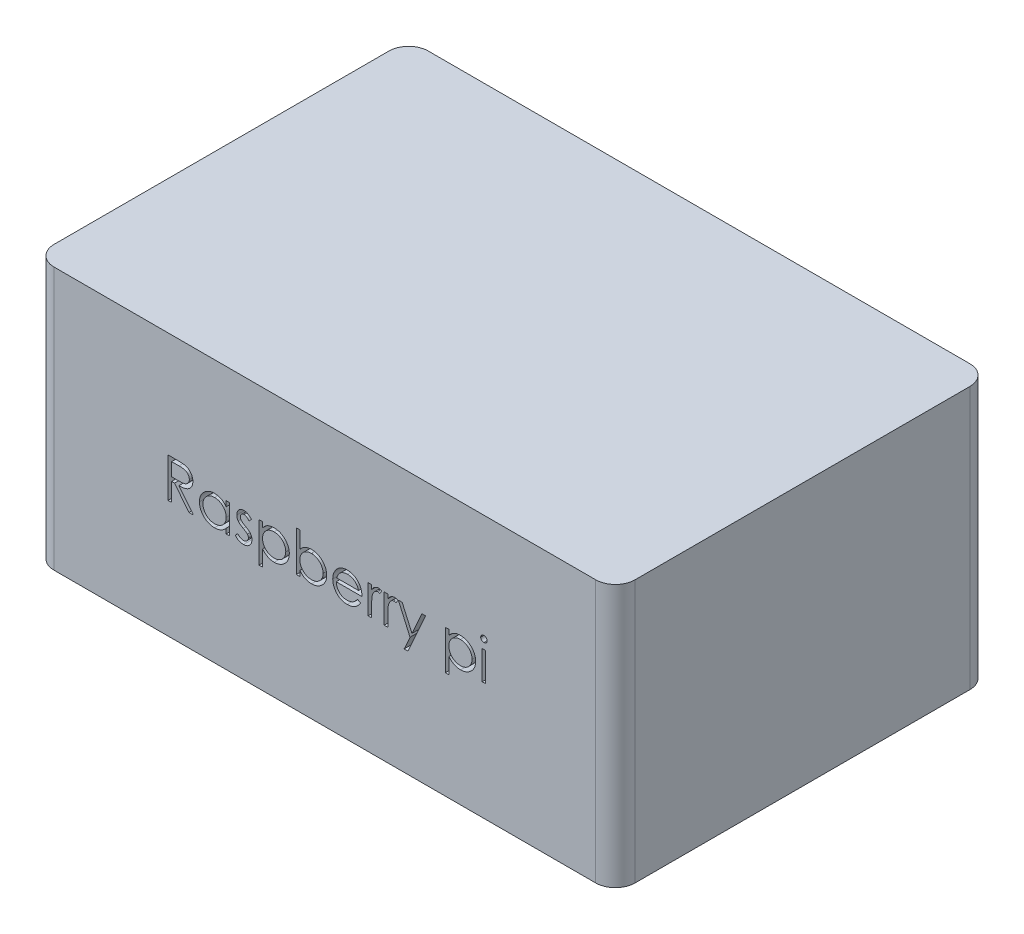
from build123d import *

# Parameters (mm, degrees)
CROQUIS1_W              = 88.5
CROQUIS1_H              = 57
SALIENTE_EXTRUIR1_DEPTH = 40
CROQUIS2_W              = 0.538461538
CROQUIS2_H              = 4.384615384
CORTAR_EXTRUIR1_DEPTH   = 4
REDONDEO1_R             = 3


with BuildPart() as part:
    # Croquis1 → Saliente-Extruir1 (new body)
    with BuildSketch(Plane(origin=(0, 0, 0), x_dir=(1, 0, 0), z_dir=(0, 1, 0))):
        with Locations((-14.949438202, 10.887640449)):
            Rectangle(CROQUIS1_W, CROQUIS1_H)
    extrude(amount=SALIENTE_EXTRUIR1_DEPTH)

    # Croquis2 → Cortar-Extruir1 (cut)
    with BuildSketch(Plane.XY.offset(17.612359551)):
        with BuildLine():
            Line((-38.833665017, 23.901066202), (-37.632943863, 23.901066202))
            add(Edge.make_bspline(
                [(-37.632943863, 23.901066202), (-37.552816215, 23.900799483), (-37.398962253, 23.900287353), (-37.178550932, 23.89743176), (-36.978275909, 23.88924715), (-36.798241898, 23.882203864), (-36.638452204, 23.869360536), (-36.498416849, 23.857085141), (-36.378780796, 23.841016008), (-36.306359336, 23.826092426), (-36.273568863, 23.819335433)],
                knots=[0, 0, 0, 0, 0.000240388, 0.000461571, 0.00066122, 0.000841705, 0.001002012, 0.001142061, 0.001263425, 0.001363841, 0.001363841, 0.001363841, 0.001363841], degree=3))
            add(Edge.make_bspline(
                [(-36.273568863, 23.819335433), (-36.229671794, 23.808489549), (-36.142814097, 23.787029154), (-36.017756841, 23.741669839), (-35.898589429, 23.689179053), (-35.785806873, 23.627526961), (-35.679974088, 23.556255911), (-35.579999841, 23.476596272), (-35.485430475, 23.388983919), (-35.400090538, 23.291209905), (-35.319623592, 23.188633032), (-35.251757375, 23.077712306), (-35.193254838, 22.961721116), (-35.146676809, 22.839479828), (-35.109171712, 22.712173933), (-35.08272673, 22.578650282), (-35.066867551, 22.439517182), (-35.065252942, 22.34461791), (-35.064434248, 22.296498894)],
                knots=[0, 0, 0, 0, 0.000135567, 0.000268242, 0.000398455, 0.000525939, 0.00065328, 0.000780735, 0.000909138, 0.001039396, 0.001169693, 0.001299773, 0.001428776, 0.001558907, 0.001691647, 0.001826477, 0.001966773, 0.002111084, 0.002111084, 0.002111084, 0.002111084], degree=3))
            add(Edge.make_bspline(
                [(-35.064434248, 22.296498894), (-35.066952531, 22.216553), (-35.071866352, 22.060557856), (-35.117680815, 21.834167773), (-35.192726278, 21.622986091), (-35.29613763, 21.427278712), (-35.42782816, 21.250860462), (-35.586099231, 21.095905396), (-35.771039136, 20.966236975), (-35.943203678, 20.876317881), (-36.095285163, 20.818730037), (-36.220485128, 20.778210565), (-36.357057089, 20.746904339), (-36.50369252, 20.718858399), (-36.661001643, 20.697684065), (-36.828607425, 20.682175618), (-37.0066294, 20.672482963), (-37.128924947, 20.671039526), (-37.191838094, 20.670296971)],
                knots=[0, 0, 0, 0, 0.000239617, 0.000467555, 0.00068957, 0.000910017, 0.001129008, 0.001347444, 0.001571557, 0.001804323, 0.001927981, 0.002059123, 0.002198764, 0.002347981, 0.002506913, 0.002674709, 0.002852853, 0.00304159, 0.00304159, 0.00304159, 0.00304159], degree=3))
            Line((-37.191838094, 20.670296971), (-34.987511171, 17.901066202))
            Line((-34.987511171, 17.901066202), (-35.653376556, 17.901066202))
            Line((-35.653376556, 17.901066202), (-37.857703479, 20.670296971))
            Line((-37.857703479, 20.670296971), (-38.295203479, 20.670296971))
            Line((-38.295203479, 20.670296971), (-38.295203479, 17.901066202))
            Line((-38.295203479, 17.901066202), (-38.833665017, 17.901066202))
            Line((-38.833665017, 17.901066202), (-38.833665017, 23.901066202))
        make_face()
        with BuildLine():
            Line((-38.295203479, 23.285681586), (-38.295203479, 21.285681586))
            Line((-38.295203479, 21.285681586), (-37.196645787, 21.277268125))
            add(Edge.make_bspline(
                [(-37.196645787, 21.277268125), (-37.145354291, 21.277245433), (-37.045936765, 21.277201451), (-36.902107054, 21.284047925), (-36.768186862, 21.29183647), (-36.64468843, 21.303749634), (-36.531556587, 21.3191029), (-36.428847878, 21.338308016), (-36.336394646, 21.36068298), (-36.22856858, 21.395314339), (-36.108163098, 21.450181799), (-35.977309167, 21.530008368), (-35.865876588, 21.630412572), (-35.771731681, 21.745224211), (-35.696081227, 21.87145778), (-35.642746277, 22.007600128), (-35.60890209, 22.150214296), (-35.604910298, 22.248233909), (-35.602895787, 22.297700817)],
                knots=[0, 0, 0, 0, 0.000153851, 0.000298207, 0.000431885, 0.000556265, 0.000670322, 0.000774279, 0.000869603, 0.000955505, 0.001113666, 0.001265404, 0.001413529, 0.001561267, 0.001709475, 0.001852988, 0.00199848, 0.002146712, 0.002146712, 0.002146712, 0.002146712], degree=3))
            add(Edge.make_bspline(
                [(-35.602895787, 22.297700817), (-35.604956566, 22.345952086), (-35.609040278, 22.441568496), (-35.642381024, 22.581550056), (-35.69876282, 22.713664828), (-35.7747438, 22.837375373), (-35.86731378, 22.949670921), (-35.975858601, 23.045751754), (-36.097410364, 23.125036551), (-36.211018133, 23.175701203), (-36.312562497, 23.206763809), (-36.400727629, 23.228622947), (-36.500347305, 23.246184894), (-36.611905234, 23.260255855), (-36.734925172, 23.272350045), (-36.870029146, 23.280495951), (-37.016320769, 23.285319719), (-37.117715508, 23.285558157), (-37.170203479, 23.285681586)],
                knots=[0, 0, 0, 0, 0.000144636, 0.000286615, 0.000428814, 0.000573933, 0.000720745, 0.000863779, 0.001007131, 0.001154551, 0.001235143, 0.001325511, 0.001426887, 0.0015384, 0.001662781, 0.001797659, 0.001944372, 0.002101829, 0.002101829, 0.002101829, 0.002101829], degree=3))
            Line((-37.170203479, 23.285681586), (-38.295203479, 23.285681586))
        make_face(mode=Mode.SUBTRACT)
        with BuildLine():
            Line((-29.449049633, 22.285681586), (-29.449049633, 17.901066202))
            Line((-29.449049633, 17.901066202), (-29.987511171, 17.901066202))
            Line((-29.987511171, 17.901066202), (-29.987511171, 18.659479663))
            add(Edge.make_bspline(
                [(-29.987511171, 18.659479663), (-30.048229098, 18.590840359), (-30.166720896, 18.456889895), (-30.364619955, 18.281891885), (-30.574393974, 18.137243333), (-30.79502481, 18.020414907), (-31.026313228, 17.932657096), (-31.26774652, 17.870280823), (-31.519423173, 17.830177105), (-31.691284353, 17.826172497), (-31.778376556, 17.824143125)],
                knots=[0, 0, 0, 0, 0.000274736, 0.000536151, 0.000790198, 0.001037514, 0.001283277, 0.001530491, 0.00178462, 0.002045714, 0.002045714, 0.002045714, 0.002045714], degree=3))
            add(Edge.make_bspline(
                [(-31.778376556, 17.824143125), (-31.855807334, 17.826245477), (-32.008504256, 17.830391409), (-32.233125532, 17.862555359), (-32.449283673, 17.914207853), (-32.657182941, 17.986037949), (-32.855478047, 18.081319358), (-33.045866785, 18.195390068), (-33.227362828, 18.331231491), (-33.397199752, 18.486525254), (-33.553597467, 18.655202375), (-33.690845363, 18.835109027), (-33.805279214, 19.025467262), (-33.900970781, 19.223866955), (-33.9746788, 19.431835388), (-34.026062173, 19.64865339), (-34.058188653, 19.874064602), (-34.062332871, 20.027560927), (-34.064434248, 20.105393125)],
                knots=[0, 0, 0, 0, 0.000232223, 0.000457954, 0.000679219, 0.000898167, 0.001116441, 0.001338029, 0.00156303, 0.001795312, 0.00202752, 0.002252283, 0.002472841, 0.002692718, 0.002912064, 0.003133329, 0.003360251, 0.003593675, 0.003593675, 0.003593675, 0.003593675], degree=3))
            add(Edge.make_bspline(
                [(-34.064434248, 20.105393125), (-34.062286297, 20.181616617), (-34.058039914, 20.332306348), (-34.026405823, 20.553926973), (-33.973209808, 20.767386849), (-33.898556355, 20.971998751), (-33.802827289, 21.168010266), (-33.68637914, 21.355560023), (-33.549203498, 21.535164704), (-33.391056514, 21.702601093), (-33.219739765, 21.857265003), (-33.036467655, 21.99168051), (-32.845799173, 22.107766537), (-32.644776869, 22.199743924), (-32.436376118, 22.274159532), (-32.21874164, 22.32564462), (-31.992778933, 22.355982885), (-31.839366661, 22.360376195), (-31.761549633, 22.362604663)],
                knots=[0, 0, 0, 0, 0.000228621, 0.000451972, 0.000670021, 0.000887513, 0.001104142, 0.001323278, 0.00154877, 0.001780915, 0.002013284, 0.002240216, 0.002461804, 0.002681742, 0.002902222, 0.003124656, 0.003351415, 0.003584839, 0.003584839, 0.003584839, 0.003584839], degree=3))
            add(Edge.make_bspline(
                [(-31.761549633, 22.362604663), (-31.67206416, 22.360139946), (-31.496587372, 22.355306753), (-31.239910784, 22.315084935), (-30.997091679, 22.247133277), (-30.766255647, 22.15470328), (-30.548231614, 22.031876887), (-30.345083641, 21.876939811), (-30.154685669, 21.690869205), (-30.044319455, 21.547948443), (-29.987511171, 21.474383509)],
                knots=[0, 0, 0, 0, 0.000268355, 0.000526231, 0.000777018, 0.001023424, 0.001270454, 0.001525265, 0.001787892, 0.002066459, 0.002066459, 0.002066459, 0.002066459], degree=3))
            Line((-29.987511171, 21.474383509), (-29.987511171, 22.285681586))
            Line((-29.987511171, 22.285681586), (-29.449049633, 22.285681586))
        make_face()
        with BuildLine():
            add(Edge.make_bspline(
                [(-31.754338094, 21.824143125), (-31.833048388, 21.821342603), (-31.988409988, 21.815814818), (-32.21648542, 21.772660255), (-32.434736987, 21.700858093), (-32.642073114, 21.602660549), (-32.835218628, 21.479182714), (-33.00783635, 21.329831772), (-33.161338124, 21.158682604), (-33.290438005, 20.966507558), (-33.395678857, 20.760487973), (-33.469679483, 20.545131794), (-33.518483907, 20.324323261), (-33.523469942, 20.174558657), (-33.52597271, 20.099383509)],
                knots=[0, 0, 0, 0, 0.000236018, 0.000465862, 0.000693534, 0.000923642, 0.001152351, 0.00137906, 0.001606338, 0.001840024, 0.002071696, 0.002298245, 0.002521713, 0.002746934, 0.002746934, 0.002746934, 0.002746934], degree=3))
            add(Edge.make_bspline(
                [(-33.52597271, 20.099383509), (-33.52277575, 20.024657611), (-33.516394361, 19.875498716), (-33.470536028, 19.654389155), (-33.393599102, 19.438982226), (-33.288612708, 19.231106237), (-33.157149923, 19.038104922), (-33.004769376, 18.863693284), (-32.829997465, 18.713711132), (-32.636407453, 18.588161006), (-32.429650932, 18.486739542), (-32.212221335, 18.416169874), (-31.988205956, 18.370607964), (-31.835887669, 18.365286004), (-31.759145787, 18.362604663)],
                knots=[0, 0, 0, 0, 0.000224103, 0.000447328, 0.000674275, 0.000908634, 0.001143991, 0.001373066, 0.00160147, 0.001832496, 0.002063643, 0.002290173, 0.0025167, 0.00274672, 0.00274672, 0.00274672, 0.00274672], degree=3))
            add(Edge.make_bspline(
                [(-31.759145787, 18.362604663), (-31.681237496, 18.365450316), (-31.526285634, 18.371110036), (-31.297533563, 18.414449348), (-31.075542198, 18.486053002), (-30.863335521, 18.585308648), (-30.665650725, 18.708321258), (-30.488225792, 18.852333414), (-30.338198417, 19.019824587), (-30.211011086, 19.203898507), (-30.111281801, 19.405690501), (-30.038637128, 19.620549113), (-29.995687575, 19.848481824), (-29.990274324, 20.004248556), (-29.987511171, 20.083758509)],
                knots=[0, 0, 0, 0, 0.000233619, 0.000464644, 0.000695745, 0.000931803, 0.001165589, 0.001392736, 0.001614832, 0.001837866, 0.002062011, 0.00228778, 0.002516443, 0.00275486, 0.00275486, 0.00275486, 0.00275486], degree=3))
            add(Edge.make_bspline(
                [(-29.987511171, 20.083758509), (-29.989156296, 20.144337647), (-29.992394423, 20.263576562), (-30.017132543, 20.438652306), (-30.056483845, 20.606195837), (-30.111934422, 20.766383303), (-30.184776624, 20.918329044), (-30.272629937, 21.063124062), (-30.377039279, 21.200015281), (-30.496323901, 21.327117689), (-30.62689282, 21.443048767), (-30.76505489, 21.546530322), (-30.912447027, 21.631539647), (-31.066590519, 21.701896112), (-31.227752807, 21.757883226), (-31.397245298, 21.795233559), (-31.573266418, 21.820879823), (-31.69334537, 21.823043905), (-31.754338094, 21.824143125)],
                knots=[0, 0, 0, 0, 0.000181685, 0.000357614, 0.000529325, 0.000697337, 0.000865073, 0.001033895, 0.001204572, 0.0013806, 0.001555973, 0.001727852, 0.001897511, 0.00206532, 0.002235604, 0.002408212, 0.002585332, 0.002768167, 0.002768167, 0.002768167, 0.002768167], degree=3))
        make_face(mode=Mode.SUBTRACT)
        with BuildLine():
            Line((-26.141357325, 21.738806586), (-26.50674194, 21.362604663))
            add(Edge.make_bspline(
                [(-26.50674194, 21.362604663), (-26.538268518, 21.399141486), (-26.599048048, 21.469580178), (-26.695444872, 21.563758006), (-26.791485336, 21.642849901), (-26.88585473, 21.709625202), (-26.980926049, 21.760109454), (-27.075583623, 21.796957788), (-27.16992546, 21.819760884), (-27.232987235, 21.822699922), (-27.263953479, 21.824143125)],
                knots=[0, 0, 0, 0, 0.000144731, 0.000279024, 0.000403677, 0.000517701, 0.000625238, 0.000725683, 0.000821897, 0.000914726, 0.000914726, 0.000914726, 0.000914726], degree=3))
            add(Edge.make_bspline(
                [(-27.263953479, 21.824143125), (-27.301906719, 21.822300485), (-27.376593323, 21.818674432), (-27.483609012, 21.78247998), (-27.58295294, 21.726922143), (-27.668936335, 21.648118856), (-27.741772357, 21.557665824), (-27.794938668, 21.456529267), (-27.827451783, 21.347761192), (-27.83157418, 21.272281436), (-27.833665017, 21.233998894)],
                knots=[0, 0, 0, 0, 0.000113497, 0.000223347, 0.000335307, 0.000452788, 0.000570858, 0.000682145, 0.000793587, 0.000908281, 0.000908281, 0.000908281, 0.000908281], degree=3))
            add(Edge.make_bspline(
                [(-27.833665017, 21.233998894), (-27.831760768, 21.199349676), (-27.827957637, 21.130148914), (-27.798391901, 21.02806657), (-27.751307206, 20.928540219), (-27.707301158, 20.867575237), (-27.684626556, 20.836162356)],
                knots=[0, 0, 0, 0, 0.000103812, 0.000207331, 0.000316468, 0.000432477, 0.000432477, 0.000432477, 0.000432477], degree=3))
            add(Edge.make_bspline(
                [(-27.684626556, 20.836162356), (-27.670974852, 20.819388782), (-27.641918922, 20.783688346), (-27.587390039, 20.734138883), (-27.525637177, 20.679380739), (-27.451374426, 20.624631875), (-27.367801236, 20.566977489), (-27.27310532, 20.508688118), (-27.170291883, 20.445320533), (-27.096685072, 20.405130072), (-27.058424633, 20.384239279)],
                knots=[0, 0, 0, 0, 6.4792e-05, 0.000137903, 0.000220556, 0.000312383, 0.000414398, 0.000525112, 0.000645904, 0.000776654, 0.000776654, 0.000776654, 0.000776654], degree=3))
            add(Edge.make_bspline(
                [(-27.058424633, 20.384239279), (-27.011772786, 20.35810516), (-26.92165678, 20.307622647), (-26.793612037, 20.229263155), (-26.677405681, 20.151380714), (-26.572053108, 20.074808244), (-26.479581435, 19.997403328), (-26.397185059, 19.922132888), (-26.326919155, 19.846722645), (-26.287569567, 19.794037307), (-26.268761171, 19.768854663)],
                knots=[0, 0, 0, 0, 0.000160411, 0.00030986, 0.000450203, 0.000580016, 0.000700358, 0.000811775, 0.000914699, 0.001008941, 0.001008941, 0.001008941, 0.001008941], degree=3))
            add(Edge.make_bspline(
                [(-26.268761171, 19.768854663), (-26.237543124, 19.717998512), (-26.175413417, 19.616785333), (-26.110170674, 19.450125172), (-26.07235306, 19.273364311), (-26.06710354, 19.152451933), (-26.064434248, 19.090970048)],
                knots=[0, 0, 0, 0, 0.000178747, 0.000355741, 0.000533958, 0.000718327, 0.000718327, 0.000718327, 0.000718327], degree=3))
            add(Edge.make_bspline(
                [(-26.064434248, 19.090970048), (-26.065667735, 19.047651512), (-26.068098455, 18.962287603), (-26.084997998, 18.836570752), (-26.114063672, 18.716340082), (-26.153652964, 18.600291023), (-26.207111889, 18.490647126), (-26.269765256, 18.384642128), (-26.34497939, 18.284569104), (-26.43085032, 18.190559458), (-26.524871167, 18.104698177), (-26.625167404, 18.029228541), (-26.731862542, 17.966529678), (-26.844194201, 17.914646229), (-26.962417608, 17.873386358), (-27.086551247, 17.844822019), (-27.216200541, 17.827725857), (-27.304365926, 17.825352469), (-27.349290017, 17.824143125)],
                knots=[0, 0, 0, 0, 0.000129947, 0.000256074, 0.00037968, 0.000500555, 0.000623128, 0.00074495, 0.000869469, 0.00099794, 0.001126411, 0.00125093, 0.001373785, 0.001496934, 0.00162161, 0.001748724, 0.001878426, 0.002013176, 0.002013176, 0.002013176, 0.002013176], degree=3))
            add(Edge.make_bspline(
                [(-27.349290017, 17.824143125), (-27.409919461, 17.825844897), (-27.530335907, 17.829224795), (-27.708432569, 17.860949471), (-27.882468155, 17.910313004), (-28.051125652, 17.978397462), (-28.210633276, 18.064370113), (-28.356572004, 18.167334216), (-28.489448797, 18.283888497), (-28.565080123, 18.373224916), (-28.602895787, 18.417893125)],
                knots=[0, 0, 0, 0, 0.000181745, 0.000360965, 0.00054092, 0.000723715, 0.000905492, 0.001083222, 0.001258596, 0.00143397, 0.00143397, 0.00143397, 0.00143397], degree=3))
            Line((-28.602895787, 18.417893125), (-28.245924633, 18.824143125))
            add(Edge.make_bspline(
                [(-28.245924633, 18.824143125), (-28.212029068, 18.787534957), (-28.14631739, 18.716564489), (-28.041229589, 18.622065619), (-27.934293473, 18.54286344), (-27.826576868, 18.476617586), (-27.716485277, 18.425574038), (-27.604635653, 18.389713591), (-27.491255497, 18.366666404), (-27.415103265, 18.363960777), (-27.376934248, 18.362604663)],
                knots=[0, 0, 0, 0, 0.000149619, 0.000290059, 0.000423234, 0.000548355, 0.000668818, 0.000786268, 0.000900122, 0.001014532, 0.001014532, 0.001014532, 0.001014532], degree=3))
            add(Edge.make_bspline(
                [(-27.376934248, 18.362604663), (-27.324960661, 18.364954649), (-27.223412989, 18.369546126), (-27.077966546, 18.41123257), (-26.943671758, 18.476598201), (-26.827060308, 18.569314827), (-26.727799461, 18.677238666), (-26.655922591, 18.798805727), (-26.610877718, 18.930448224), (-26.605587435, 19.0217036), (-26.602895787, 19.068133509)],
                knots=[0, 0, 0, 0, 0.000155611, 0.000304037, 0.000450243, 0.000600987, 0.000748217, 0.000887769, 0.001021938, 0.00116091, 0.00116091, 0.00116091, 0.00116091], degree=3))
            add(Edge.make_bspline(
                [(-26.602895787, 19.068133509), (-26.604758005, 19.10637857), (-26.608434707, 19.181888323), (-26.637308888, 19.291174621), (-26.68293092, 19.394836246), (-26.727853175, 19.455504212), (-26.750732325, 19.48640274)],
                knots=[0, 0, 0, 0, 0.000114587, 0.000226236, 0.000337048, 0.000452063, 0.000452063, 0.000452063, 0.000452063], degree=3))
            add(Edge.make_bspline(
                [(-26.750732325, 19.48640274), (-26.764485001, 19.501891932), (-26.794443297, 19.535632987), (-26.849395139, 19.584361694), (-26.915192617, 19.63688415), (-26.992575754, 19.692309731), (-27.081700545, 19.74990734), (-27.182928218, 19.809374801), (-27.294872022, 19.873536616), (-27.374021676, 19.916084597), (-27.415395787, 19.938325817)],
                knots=[0, 0, 0, 0, 6.2094e-05, 0.000135264, 0.00021992, 0.000314651, 0.000420666, 0.00053816, 0.000666816, 0.000807729, 0.000807729, 0.000807729, 0.000807729], degree=3))
            add(Edge.make_bspline(
                [(-27.415395787, 19.938325817), (-27.460047169, 19.963250043), (-27.546640451, 20.011586071), (-27.66929295, 20.08687078), (-27.779945557, 20.163443251), (-27.881260828, 20.237008118), (-27.970679694, 20.311444022), (-28.047849892, 20.386833596), (-28.11580969, 20.460136429), (-28.153433825, 20.512074652), (-28.171405402, 20.536883509)],
                knots=[0, 0, 0, 0, 0.000153404, 0.0002975, 0.000431518, 0.000557003, 0.000673036, 0.000780136, 0.000880552, 0.000972379, 0.000972379, 0.000972379, 0.000972379], degree=3))
            add(Edge.make_bspline(
                [(-28.171405402, 20.536883509), (-28.20248643, 20.586847421), (-28.264659347, 20.686792704), (-28.325028247, 20.853610664), (-28.366524296, 21.029230763), (-28.370231251, 21.150408227), (-28.372126556, 21.212364279)],
                knots=[0, 0, 0, 0, 0.000176064, 0.00035219, 0.000529489, 0.000714975, 0.000714975, 0.000714975, 0.000714975], degree=3))
            add(Edge.make_bspline(
                [(-28.372126556, 21.212364279), (-28.371210792, 21.252864961), (-28.369418514, 21.332130534), (-28.355114425, 21.448597083), (-28.329071492, 21.559251061), (-28.29640591, 21.665754255), (-28.251006474, 21.766043559), (-28.196756351, 21.861456366), (-28.13300648, 21.951860797), (-28.059560838, 22.035866167), (-27.978806589, 22.112167869), (-27.891558412, 22.178679802), (-27.799778544, 22.235433554), (-27.703078396, 22.283030972), (-27.600529014, 22.319033342), (-27.492847209, 22.343817431), (-27.380250943, 22.360369207), (-27.303277585, 22.36184878), (-27.263953479, 22.362604663)],
                knots=[0, 0, 0, 0, 0.000121489, 0.000237772, 0.000351193, 0.000462187, 0.00057141, 0.000680686, 0.000791067, 0.000902665, 0.001014901, 0.0011238, 0.001231202, 0.001338173, 0.001446513, 0.001556422, 0.001669288, 0.001787174, 0.001787174, 0.001787174, 0.001787174], degree=3))
            add(Edge.make_bspline(
                [(-27.263953479, 22.362604663), (-27.217338513, 22.360711508), (-27.123234133, 22.356889683), (-26.982054774, 22.326537071), (-26.84108333, 22.276594607), (-26.699957587, 22.207618207), (-26.559711377, 22.118360705), (-26.419111051, 22.010481906), (-26.276468714, 21.884691538), (-26.187400748, 21.788521438), (-26.141357325, 21.738806586)],
                knots=[0, 0, 0, 0, 0.000139754, 0.00028213, 0.00043114, 0.000587565, 0.000752299, 0.000928986, 0.001118832, 0.001322, 0.001322, 0.001322, 0.001322], degree=3))
        make_face()
        with BuildLine():
            Line((-24.987511171, 22.285681586), (-24.449049633, 22.285681586))
            Line((-24.449049633, 22.285681586), (-24.449049633, 21.474383509))
            add(Edge.make_bspline(
                [(-24.449049633, 21.474383509), (-24.391865374, 21.547991053), (-24.280739212, 21.691032584), (-24.089210804, 21.876158519), (-23.88705056, 22.032287611), (-23.669056138, 22.154657667), (-23.438615527, 22.246921916), (-23.196674411, 22.315115259), (-22.941179386, 22.355300644), (-22.766499753, 22.360137777), (-22.677415017, 22.362604663)],
                knots=[0, 0, 0, 0, 0.000279325, 0.000542812, 0.000796666, 0.001043695, 0.001290101, 0.001539731, 0.00179642, 0.002063574, 0.002063574, 0.002063574, 0.002063574], degree=3))
            add(Edge.make_bspline(
                [(-22.677415017, 22.362604663), (-22.59960084, 22.360353499), (-22.445797032, 22.355903956), (-22.219402925, 22.32577872), (-22.001387982, 22.27414839), (-21.792985604, 22.19974682), (-21.591963206, 22.107766015), (-21.401296749, 21.991679668), (-21.218016368, 21.857269055), (-21.046731473, 21.702585368), (-20.888466271, 21.535222626), (-20.751587104, 21.35518439), (-20.633520982, 21.168391385), (-20.538086188, 20.971947798), (-20.463329021, 20.767400547), (-20.410161002, 20.55392322), (-20.378519328, 20.332307322), (-20.374273982, 20.181616944), (-20.372126556, 20.105393125)],
                knots=[0, 0, 0, 0, 0.000233424, 0.000461375, 0.000683808, 0.000904288, 0.001124227, 0.001345815, 0.001572746, 0.001805115, 0.002037261, 0.002262752, 0.002482523, 0.002699153, 0.002916645, 0.003134694, 0.003358044, 0.003586666, 0.003586666, 0.003586666, 0.003586666], degree=3))
            add(Edge.make_bspline(
                [(-20.372126556, 20.105393125), (-20.374227388, 20.027560596), (-20.378370533, 19.874063617), (-20.410504829, 19.648657164), (-20.46185947, 19.431821666), (-20.535673498, 19.223917786), (-20.631058907, 19.025088669), (-20.747123868, 18.835477705), (-20.884072097, 18.655145642), (-21.040588316, 18.486540671), (-21.210393349, 18.331227563), (-21.391897617, 18.195390872), (-21.582284346, 18.081319943), (-21.78057949, 17.986034869), (-21.988480584, 17.914219697), (-22.205017632, 17.862417753), (-22.43007274, 17.830472903), (-22.583160429, 17.82626923), (-22.660588094, 17.824143125)],
                knots=[0, 0, 0, 0, 0.000233424, 0.000460346, 0.00068161, 0.000900957, 0.001120834, 0.001342017, 0.00156678, 0.001798987, 0.00203127, 0.00225627, 0.002477858, 0.002696132, 0.00291508, 0.003136345, 0.003363267, 0.00359549, 0.00359549, 0.00359549, 0.00359549], degree=3))
            add(Edge.make_bspline(
                [(-22.660588094, 17.824143125), (-22.747721075, 17.826362795), (-22.919834257, 17.830747295), (-23.171487406, 17.875180569), (-23.413676295, 17.941586745), (-23.643717709, 18.03878502), (-23.863433959, 18.162651618), (-24.071582197, 18.313697686), (-24.269268059, 18.491607328), (-24.3882545, 18.626576156), (-24.449049633, 18.695537356)],
                knots=[0, 0, 0, 0, 0.000261152, 0.000515852, 0.000764325, 0.001013216, 0.00126293, 0.001519461, 0.001783277, 0.002058897, 0.002058897, 0.002058897, 0.002058897], degree=3))
            Line((-24.449049633, 18.695537356), (-24.449049633, 16.285681586))
            Line((-24.449049633, 16.285681586), (-24.987511171, 16.285681586))
            Line((-24.987511171, 16.285681586), (-24.987511171, 22.285681586))
        make_face()
        with BuildLine():
            add(Edge.make_bspline(
                [(-22.68222271, 21.824143125), (-22.743216245, 21.823045539), (-22.863296796, 21.820884676), (-23.039306314, 21.79521505), (-23.208841333, 21.757950351), (-23.37019325, 21.70152995), (-23.524908592, 21.632274842), (-23.671795732, 21.545734251), (-23.810751562, 21.44347367), (-23.941426471, 21.327451937), (-24.059477831, 21.199609615), (-24.163985708, 21.063173371), (-24.25176966, 20.918315989), (-24.324630266, 20.766386796), (-24.380075893, 20.606194878), (-24.419428556, 20.438652571), (-24.444166303, 20.263576492), (-24.447404482, 20.144337624), (-24.449049633, 20.083758509)],
                knots=[0, 0, 0, 0, 0.000182835, 0.000359954, 0.000532563, 0.000702846, 0.00087175, 0.001040371, 0.001213218, 0.001388591, 0.0015638, 0.001734478, 0.0019033, 0.002071036, 0.002239047, 0.002410758, 0.002586687, 0.002768372, 0.002768372, 0.002768372, 0.002768372], degree=3))
            add(Edge.make_bspline(
                [(-24.449049633, 20.083758509), (-24.446322451, 20.004236031), (-24.440979671, 19.84844476), (-24.397544183, 19.620814837), (-24.326855159, 19.405411999), (-24.226520221, 19.204050221), (-24.099752951, 19.01893679), (-23.947013254, 18.853181464), (-23.769683166, 18.707826165), (-23.570710838, 18.58538973), (-23.357415757, 18.485981617), (-23.134925622, 18.414814399), (-22.906300112, 18.370976293), (-22.751725849, 18.365410317), (-22.673809248, 18.362604663)],
                knots=[0, 0, 0, 0, 0.000238417, 0.00046708, 0.000692469, 0.000916614, 0.001139647, 0.001363363, 0.001590511, 0.001825317, 0.002062464, 0.002294709, 0.002524553, 0.002758172, 0.002758172, 0.002758172, 0.002758172], degree=3))
            add(Edge.make_bspline(
                [(-22.673809248, 18.362604663), (-22.597462217, 18.365272738), (-22.445927087, 18.370568386), (-22.222798878, 18.41640528), (-22.005957784, 18.486425322), (-21.799934631, 18.588527418), (-21.606522938, 18.713653232), (-21.431868846, 18.863756146), (-21.279285566, 19.037738906), (-21.149232385, 19.231467768), (-21.044435553, 19.439196997), (-20.965697999, 19.65413652), (-20.920254731, 19.875528674), (-20.913814522, 20.024667611), (-20.910588094, 20.099383509)],
                knots=[0, 0, 0, 0, 0.00022882, 0.000454167, 0.000680697, 0.000910764, 0.00114179, 0.001370193, 0.001599269, 0.001833952, 0.002068312, 0.002295663, 0.002518887, 0.002742991, 0.002742991, 0.002742991, 0.002742991], degree=3))
            add(Edge.make_bspline(
                [(-20.910588094, 20.099383509), (-20.913081924, 20.174563491), (-20.918050153, 20.324337726), (-20.966987932, 20.545074131), (-21.040530751, 20.76088209), (-21.14777484, 20.965774461), (-21.274977016, 21.15910146), (-21.428829011, 21.329765252), (-21.601313919, 21.479200691), (-21.794495343, 21.602655679), (-22.001821787, 21.700859385), (-22.220075928, 21.772659909), (-22.448150675, 21.815814908), (-22.603512369, 21.821342633), (-22.68222271, 21.824143125)],
                knots=[0, 0, 0, 0, 0.000225222, 0.000448689, 0.000675238, 0.000907455, 0.00114047, 0.001367748, 0.001594456, 0.001823166, 0.002053274, 0.002280946, 0.00251079, 0.002746808, 0.002746808, 0.002746808, 0.002746808], degree=3))
        make_face(mode=Mode.SUBTRACT)
        with BuildLine():
            Line((-19.295203479, 17.901066202), (-19.295203479, 24.054912356))
            Line((-19.295203479, 24.054912356), (-18.75674194, 24.054912356))
            Line((-18.75674194, 24.054912356), (-18.75674194, 21.490008509))
            add(Edge.make_bspline(
                [(-18.75674194, 21.490008509), (-18.696067508, 21.55987925), (-18.577689189, 21.696199945), (-18.379215272, 21.874224487), (-18.171091439, 22.025171591), (-17.951734429, 22.149604937), (-17.720832258, 22.244359692), (-17.479577214, 22.313655217), (-17.227352573, 22.355461337), (-17.055376846, 22.360203177), (-16.968280402, 22.362604663)],
                knots=[0, 0, 0, 0, 0.000277397, 0.000541213, 0.000797744, 0.001047458, 0.001295887, 0.001544688, 0.001799192, 0.002060344, 0.002060344, 0.002060344, 0.002060344], degree=3))
            add(Edge.make_bspline(
                [(-16.968280402, 22.362604663), (-16.890852737, 22.360478558), (-16.737765048, 22.356274885), (-16.512709939, 22.324330036), (-16.296172896, 22.27252809), (-16.088271785, 22.200712925), (-15.889976701, 22.105427821), (-15.699589746, 21.991357008), (-15.518086344, 21.855519872), (-15.348277969, 21.700208482), (-15.191774164, 21.531597129), (-15.054781289, 21.351288017), (-14.939067524, 21.161902148), (-14.843356737, 20.964073469), (-14.769349218, 20.75699401), (-14.718362474, 20.540866813), (-14.685973678, 20.315904495), (-14.681893256, 20.162796832), (-14.679818863, 20.084960433)],
                knots=[0, 0, 0, 0, 0.000232223, 0.000459145, 0.00068041, 0.000899358, 0.001117632, 0.00133922, 0.00156422, 0.001796502, 0.00202871, 0.002253473, 0.002474656, 0.002693449, 0.002911664, 0.003132928, 0.00335866, 0.003592084, 0.003592084, 0.003592084, 0.003592084], degree=3))
            add(Edge.make_bspline(
                [(-14.679818863, 20.084960433), (-14.681938476, 20.008331831), (-14.686118017, 19.857232296), (-14.71804026, 19.634878199), (-14.770748142, 19.420869001), (-14.846110171, 19.215757703), (-14.940850066, 19.018580709), (-15.059326538, 18.83158573), (-15.196145395, 18.651518915), (-15.354427363, 18.484164118), (-15.52570774, 18.329478289), (-15.708989299, 18.195068235), (-15.89965545, 18.078981743), (-16.100677928, 17.987000976), (-16.309080285, 17.912599396), (-16.527095234, 17.860969069), (-16.753489339, 17.830843832), (-16.907293148, 17.826394289), (-16.985107325, 17.824143125)],
                knots=[0, 0, 0, 0, 0.000229822, 0.000453173, 0.000672388, 0.00088988, 0.00110759, 0.001327361, 0.001552853, 0.001784998, 0.002017367, 0.002244299, 0.002465887, 0.002685825, 0.002906305, 0.003128739, 0.00335669, 0.003590114, 0.003590114, 0.003590114, 0.003590114], degree=3))
            add(Edge.make_bspline(
                [(-16.985107325, 17.824143125), (-17.074190375, 17.826612739), (-17.248866702, 17.831455222), (-17.504385557, 17.871602043), (-17.746239642, 17.939936232), (-17.97718401, 18.031756385), (-18.19391725, 18.15609122), (-18.397815391, 18.310302792), (-18.587592601, 18.496932169), (-18.699392856, 18.639323294), (-18.75674194, 18.712364279)],
                knots=[0, 0, 0, 0, 0.000267154, 0.000523843, 0.000773473, 0.001019879, 0.001267501, 0.001520628, 0.001784955, 0.002063351, 0.002063351, 0.002063351, 0.002063351], degree=3))
            Line((-18.75674194, 18.712364279), (-18.75674194, 17.901066202))
            Line((-18.75674194, 17.901066202), (-19.295203479, 17.901066202))
        make_face()
        with BuildLine():
            add(Edge.make_bspline(
                [(-16.989915017, 18.362604663), (-16.911204699, 18.36540517), (-16.755843049, 18.370932925), (-16.52776798, 18.414087707), (-16.309515049, 18.485889045), (-16.102184051, 18.584089688), (-15.909019516, 18.707556033), (-15.736472144, 18.856949469), (-15.583078356, 19.027523494), (-15.455103883, 19.219924111), (-15.348258893, 19.424697201), (-15.274864705, 19.640104575), (-15.225630897, 19.860381356), (-15.220741242, 20.009774575), (-15.218280402, 20.084960433)],
                knots=[0, 0, 0, 0, 0.000236018, 0.000465862, 0.000693534, 0.000923642, 0.001152351, 0.00137906, 0.001606338, 0.001838356, 0.002070573, 0.002297121, 0.002519412, 0.002744634, 0.002744634, 0.002744634, 0.002744634], degree=3))
            add(Edge.make_bspline(
                [(-15.218280402, 20.084960433), (-15.221516534, 20.16007279), (-15.22797588, 20.309997637), (-15.273189793, 20.53225421), (-15.352146004, 20.747547281), (-15.456919758, 20.955280975), (-15.586979161, 21.149008633), (-15.739560813, 21.322991708), (-15.914215338, 21.473094538), (-16.107626914, 21.598220375), (-16.313650098, 21.700322465), (-16.530491184, 21.770342509), (-16.753619395, 21.816179402), (-16.905154525, 21.82147505), (-16.981501556, 21.824143125)],
                knots=[0, 0, 0, 0, 0.000225302, 0.000449705, 0.000677056, 0.000911415, 0.001146098, 0.001375174, 0.001603578, 0.001834603, 0.00206467, 0.0022912, 0.002516547, 0.002745367, 0.002745367, 0.002745367, 0.002745367], degree=3))
            add(Edge.make_bspline(
                [(-16.981501556, 21.824143125), (-17.059445854, 21.821476558), (-17.214149471, 21.816183963), (-17.442437852, 21.770261979), (-17.665403481, 21.699894645), (-17.878467822, 21.598869475), (-18.077074774, 21.475249828), (-18.254696395, 21.329980915), (-18.407836208, 21.164072501), (-18.533911244, 20.978062555), (-18.634033756, 20.777173923), (-18.705663038, 20.562867289), (-18.748519576, 20.336270753), (-18.753967803, 20.180899543), (-18.75674194, 20.101787356)],
                knots=[0, 0, 0, 0, 0.000233619, 0.000463686, 0.000695931, 0.000933587, 0.001169029, 0.001396176, 0.001619892, 0.001843918, 0.002068063, 0.002291171, 0.002519833, 0.002757051, 0.002757051, 0.002757051, 0.002757051], degree=3))
            add(Edge.make_bspline(
                [(-18.75674194, 20.101787356), (-18.755096791, 20.041208238), (-18.751858617, 19.921969365), (-18.727120842, 19.746893324), (-18.687768279, 19.57935088), (-18.632322289, 19.419159459), (-18.55946303, 19.26722842), (-18.471674003, 19.122377997), (-18.367185466, 18.985915234), (-18.249059884, 18.858174685), (-18.11883866, 18.741929974), (-17.979084742, 18.641167303), (-17.832654004, 18.55440012), (-17.677871196, 18.485237532), (-17.516537556, 18.428792068), (-17.346997542, 18.391534219), (-17.170989387, 18.365862724), (-17.050908648, 18.363702118), (-16.989915017, 18.362604663)],
                knots=[0, 0, 0, 0, 0.000181685, 0.000357614, 0.000529325, 0.000697337, 0.000865073, 0.001033895, 0.001204572, 0.001379781, 0.001555155, 0.001727294, 0.001895915, 0.002064818, 0.002235102, 0.002407711, 0.00258483, 0.002767665, 0.002767665, 0.002767665, 0.002767665], degree=3))
        make_face(mode=Mode.SUBTRACT)
        with BuildLine():
            Line((-10.004338094, 19.285681586), (-9.52597271, 19.034479663))
            add(Edge.make_bspline(
                [(-9.52597271, 19.034479663), (-9.564092587, 18.966862524), (-9.638258773, 18.835306348), (-9.765802912, 18.654566015), (-9.899503608, 18.491969931), (-10.045396125, 18.351861952), (-10.199115574, 18.229716721), (-10.361514411, 18.122851879), (-10.533438099, 18.031791558), (-10.71489477, 17.955072939), (-10.907408286, 17.896085235), (-11.111445171, 17.854420856), (-11.327396306, 17.828666681), (-11.475418329, 17.825675011), (-11.551213094, 17.824143125)],
                knots=[0, 0, 0, 0, 0.00023273, 0.0004528, 0.000662707, 0.000863309, 0.001058339, 0.001251022, 0.001445663, 0.001641208, 0.001841183, 0.002048618, 0.002265238, 0.002492557, 0.002492557, 0.002492557, 0.002492557], degree=3))
            add(Edge.make_bspline(
                [(-11.551213094, 17.824143125), (-11.635456484, 17.826109711), (-11.799790933, 17.829945951), (-12.039001928, 17.863018747), (-12.264223788, 17.916971362), (-12.475443851, 17.992340862), (-12.672144855, 18.090787703), (-12.854717749, 18.210718244), (-13.024122651, 18.351516394), (-13.175021295, 18.514401726), (-13.310867951, 18.688713653), (-13.430740785, 18.870352312), (-13.530953524, 19.058860697), (-13.612472285, 19.253038738), (-13.678309196, 19.451662556), (-13.724194974, 19.656539357), (-13.750645971, 19.867114644), (-13.754699306, 20.00956722), (-13.75674194, 20.081354663)],
                knots=[0, 0, 0, 0, 0.000252636, 0.000492819, 0.000722826, 0.000946377, 0.001164071, 0.001381091, 0.001600385, 0.00182316, 0.002045798, 0.002262817, 0.002475204, 0.002685266, 0.002893934, 0.00310213, 0.003314122, 0.003529481, 0.003529481, 0.003529481, 0.003529481], degree=3))
            add(Edge.make_bspline(
                [(-13.75674194, 20.081354663), (-13.75492627, 20.14871723), (-13.75132785, 20.282220941), (-13.7286465, 20.479819017), (-13.688449426, 20.671867793), (-13.633290014, 20.858526846), (-13.562059306, 21.039483648), (-13.474918359, 21.214848328), (-13.371731425, 21.384434282), (-13.292063985, 21.491411083), (-13.251934248, 21.545296971)],
                knots=[0, 0, 0, 0, 0.000202098, 0.000400532, 0.00059571, 0.00079004, 0.000983773, 0.001178355, 0.001376861, 0.00157834, 0.00157834, 0.00157834, 0.00157834], degree=3))
            add(Edge.make_bspline(
                [(-13.251934248, 21.545296971), (-13.19757822, 21.610215034), (-13.090588026, 21.73799472), (-12.909634274, 21.905888993), (-12.713691081, 22.046535465), (-12.505214007, 22.163119127), (-12.281780052, 22.251702522), (-12.046392696, 22.31771552), (-11.796371691, 22.354706396), (-11.625448455, 22.359931254), (-11.53799194, 22.362604663)],
                knots=[0, 0, 0, 0, 0.000253836, 0.000499632, 0.000738137, 0.000975939, 0.001214308, 0.001457503, 0.001707887, 0.00197024, 0.00197024, 0.00197024, 0.00197024], degree=3))
            add(Edge.make_bspline(
                [(-11.53799194, 22.362604663), (-11.44808176, 22.360283437), (-11.271698481, 22.355729719), (-11.014500559, 22.313513147), (-10.771139331, 22.246565911), (-10.541712181, 22.152016556), (-10.326195848, 22.030028753), (-10.125991192, 21.878928453), (-9.937674313, 21.703354589), (-9.828116749, 21.568331945), (-9.77236694, 21.499623894)],
                knots=[0, 0, 0, 0, 0.000269555, 0.000528806, 0.000779593, 0.001025342, 0.001271325, 0.001520364, 0.001776295, 0.002041463, 0.002041463, 0.002041463, 0.002041463], degree=3))
            add(Edge.make_bspline(
                [(-9.77236694, 21.499623894), (-9.734435046, 21.447846326), (-9.658823744, 21.344635837), (-9.564114429, 21.176342425), (-9.481901752, 21.00026712), (-9.416188105, 20.813563754), (-9.362977531, 20.618444473), (-9.324480128, 20.413514397), (-9.301903639, 20.198834549), (-9.297465872, 20.052560453), (-9.295203479, 19.977989279)],
                knots=[0, 0, 0, 0, 0.000192402, 0.000383522, 0.000578193, 0.00077474, 0.000976505, 0.001184421, 0.001399578, 0.001623343, 0.001623343, 0.001623343, 0.001623343], degree=3))
            Line((-9.295203479, 19.977989279), (-13.218280402, 19.977989279))
            add(Edge.make_bspline(
                [(-13.218280402, 19.977989279), (-13.215641077, 19.920217054), (-13.21045095, 19.806610305), (-13.186253562, 19.640374677), (-13.148112807, 19.482020376), (-13.094508699, 19.332735161), (-13.029594107, 19.190569228), (-12.950075736, 19.056577165), (-12.855207929, 18.931369285), (-12.749392444, 18.81382562), (-12.631608852, 18.70915003), (-12.507695571, 18.615461271), (-12.375878031, 18.53693739), (-12.237195602, 18.473200437), (-12.091872542, 18.423303895), (-11.939863065, 18.389244774), (-11.781466294, 18.36643259), (-11.67349075, 18.363896021), (-11.618520787, 18.362604663)],
                knots=[0, 0, 0, 0, 0.000173415, 0.000341013, 0.000503094, 0.000661237, 0.000816118, 0.000971333, 0.001127583, 0.001286696, 0.001445004, 0.001599571, 0.001752107, 0.001904301, 0.002056718, 0.002212119, 0.002371051, 0.002535872, 0.002535872, 0.002535872, 0.002535872], degree=3))
            add(Edge.make_bspline(
                [(-11.618520787, 18.362604663), (-11.564775962, 18.363647046), (-11.458135921, 18.365715334), (-11.299323022, 18.385827181), (-11.143083832, 18.418347653), (-10.990065004, 18.462730494), (-10.843372125, 18.51686224), (-10.707522611, 18.582181425), (-10.582585098, 18.654438133), (-10.465813156, 18.737083291), (-10.352548596, 18.838240183), (-10.240190047, 18.964472847), (-10.119715785, 19.113765752), (-10.044305054, 19.226129751), (-10.004338094, 19.285681586)],
                knots=[0, 0, 0, 0, 0.00016117, 0.000319792, 0.000479376, 0.000639521, 0.000797358, 0.000947886, 0.001091157, 0.0012299, 0.001376328, 0.001545628, 0.00173634, 0.001951391, 0.001951391, 0.001951391, 0.001951391], degree=3))
        make_face()
        with BuildLine():
            add(Edge.make_bspline(
                [(-9.833665017, 20.516450817), (-9.853373517, 20.587872886), (-9.891306033, 20.725337379), (-9.970568372, 20.915693191), (-10.059833871, 21.08487245), (-10.165471125, 21.231580392), (-10.285160369, 21.361872129), (-10.423409253, 21.475732561), (-10.578442213, 21.577591048), (-10.749457883, 21.663566761), (-10.930558086, 21.736749376), (-11.120168701, 21.785821003), (-11.313639194, 21.819437362), (-11.444497971, 21.822567833), (-11.51034771, 21.824143125)],
                knots=[0, 0, 0, 0, 0.000222073, 0.000427419, 0.000617254, 0.0007947, 0.00096821, 0.001146569, 0.001330585, 0.00152356, 0.001719971, 0.001915308, 0.002110139, 0.002307488, 0.002307488, 0.002307488, 0.002307488], degree=3))
            add(Edge.make_bspline(
                [(-11.51034771, 21.824143125), (-11.564089604, 21.823094545), (-11.670326031, 21.821021723), (-11.826842148, 21.801358644), (-11.977150203, 21.768856053), (-12.122359268, 21.724344699), (-12.260566471, 21.665015666), (-12.394614645, 21.595444421), (-12.521095324, 21.510515991), (-12.600194688, 21.445786526), (-12.640155402, 21.413085433)],
                knots=[0, 0, 0, 0, 0.00016117, 0.000318599, 0.000472304, 0.000622087, 0.000773439, 0.000922903, 0.001074579, 0.00122944, 0.00122944, 0.00122944, 0.00122944], degree=3))
            add(Edge.make_bspline(
                [(-12.640155402, 21.413085433), (-12.668772457, 21.387209463), (-12.726686401, 21.334842807), (-12.804070152, 21.24462131), (-12.878162391, 21.147332918), (-12.94559151, 21.039255561), (-13.007438801, 20.92161994), (-13.065313048, 20.79541828), (-13.11740404, 20.659692913), (-13.146711657, 20.565111589), (-13.161790017, 20.516450817)],
                knots=[0, 0, 0, 0, 0.000115635, 0.000234017, 0.000355892, 0.000482277, 0.00061562, 0.000754383, 0.000898579, 0.001051379, 0.001051379, 0.001051379, 0.001051379], degree=3))
            Line((-13.161790017, 20.516450817), (-9.833665017, 20.516450817))
        make_face(mode=Mode.SUBTRACT)
        with BuildLine():
            Line((-8.372126556, 22.285681586), (-7.833665017, 22.285681586))
            Line((-7.833665017, 22.285681586), (-7.833665017, 21.640248894))
            add(Edge.make_bspline(
                [(-7.833665017, 21.640248894), (-7.793912859, 21.7003446), (-7.717887166, 21.81527717), (-7.591522145, 21.967281686), (-7.462087863, 22.093136052), (-7.328964684, 22.193427798), (-7.191173656, 22.268536002), (-7.051738881, 22.323552633), (-6.908466647, 22.356085174), (-6.812189063, 22.360428589), (-6.763953479, 22.362604663)],
                knots=[0, 0, 0, 0, 0.000216039, 0.000413172, 0.000591681, 0.000756586, 0.000911503, 0.00106105, 0.001205105, 0.001349741, 0.001349741, 0.001349741, 0.001349741], degree=3))
            add(Edge.make_bspline(
                [(-6.763953479, 22.362604663), (-6.726536919, 22.360563761), (-6.649549916, 22.356364471), (-6.533008333, 22.3268602), (-6.412933844, 22.279755018), (-6.335546895, 22.235457494), (-6.295203479, 22.212364279)],
                knots=[0, 0, 0, 0, 0.000112192, 0.000230842, 0.000358732, 0.000498015, 0.000498015, 0.000498015, 0.000498015], degree=3))
            Line((-6.295203479, 22.212364279), (-6.590876556, 21.746018125))
            add(Edge.make_bspline(
                [(-6.590876556, 21.746018125), (-6.616777735, 21.757572867), (-6.665943131, 21.779505979), (-6.737865245, 21.805463711), (-6.804176108, 21.820748138), (-6.846422208, 21.823063653), (-6.86611694, 21.824143125)],
                knots=[0, 0, 0, 0, 8.5065e-05, 0.00016147, 0.000229131, 0.000288221, 0.000288221, 0.000288221, 0.000288221], degree=3))
            add(Edge.make_bspline(
                [(-6.86611694, 21.824143125), (-6.909326769, 21.821263061), (-6.997462295, 21.815388565), (-7.126864294, 21.769207752), (-7.252430932, 21.694593054), (-7.352153782, 21.611842577), (-7.429369072, 21.532046353), (-7.484466602, 21.462363377), (-7.535008454, 21.38422858), (-7.58330026, 21.298977693), (-7.627299622, 21.2051551), (-7.668364769, 21.103698163), (-7.705494248, 20.994489371), (-7.726666095, 20.91840505), (-7.737511171, 20.879431586)],
                knots=[0, 0, 0, 0, 0.000129412, 0.000263963, 0.000407234, 0.000566052, 0.000651057, 0.000740032, 0.00083204, 0.000929988, 0.001033751, 0.001142669, 0.001258216, 0.001379563, 0.001379563, 0.001379563, 0.001379563], degree=3))
            add(Edge.make_bspline(
                [(-7.737511171, 20.879431586), (-7.745623846, 20.844670717), (-7.763592803, 20.767678034), (-7.78106401, 20.638509134), (-7.798326041, 20.485897148), (-7.810491673, 20.309417275), (-7.821768316, 20.109510228), (-7.828128457, 19.885871464), (-7.833448127, 19.638271433), (-7.833590527, 19.465172542), (-7.833665017, 19.374623894)],
                knots=[0, 0, 0, 0, 0.000107032, 0.000237068, 0.000390636, 0.000567813, 0.000767625, 0.000991299, 0.001238942, 0.001510579, 0.001510579, 0.001510579, 0.001510579], degree=3))
            Line((-7.833665017, 19.374623894), (-7.833665017, 17.901066202))
            Line((-7.833665017, 17.901066202), (-8.372126556, 17.901066202))
            Line((-8.372126556, 17.901066202), (-8.372126556, 22.285681586))
        make_face()
        with BuildLine():
            Line((-5.910588094, 22.285681586), (-5.372126556, 22.285681586))
            Line((-5.372126556, 22.285681586), (-5.372126556, 21.640248894))
            add(Edge.make_bspline(
                [(-5.372126556, 21.640248894), (-5.332374398, 21.7003446), (-5.256348705, 21.81527717), (-5.129983683, 21.967281686), (-5.000549401, 22.093136052), (-4.867426223, 22.193427798), (-4.729635194, 22.268536002), (-4.59020042, 22.323552633), (-4.446928186, 22.356085174), (-4.350650602, 22.360428589), (-4.302415017, 22.362604663)],
                knots=[0, 0, 0, 0, 0.000216039, 0.000413172, 0.000591681, 0.000756586, 0.000911503, 0.00106105, 0.001205105, 0.001349741, 0.001349741, 0.001349741, 0.001349741], degree=3))
            add(Edge.make_bspline(
                [(-4.302415017, 22.362604663), (-4.264998458, 22.360563761), (-4.188011454, 22.356364471), (-4.071469872, 22.3268602), (-3.951395383, 22.279755018), (-3.874008433, 22.235457494), (-3.833665017, 22.212364279)],
                knots=[0, 0, 0, 0, 0.000112192, 0.000230842, 0.000358732, 0.000498015, 0.000498015, 0.000498015, 0.000498015], degree=3))
            Line((-3.833665017, 22.212364279), (-4.129338094, 21.746018125))
            add(Edge.make_bspline(
                [(-4.129338094, 21.746018125), (-4.155239273, 21.757572867), (-4.20440467, 21.779505979), (-4.276326783, 21.805463711), (-4.342637646, 21.820748138), (-4.384883746, 21.823063653), (-4.404578479, 21.824143125)],
                knots=[0, 0, 0, 0, 8.5065e-05, 0.00016147, 0.000229131, 0.000288221, 0.000288221, 0.000288221, 0.000288221], degree=3))
            add(Edge.make_bspline(
                [(-4.404578479, 21.824143125), (-4.447788308, 21.821263061), (-4.535923833, 21.815388565), (-4.665325832, 21.769207752), (-4.79089247, 21.694593054), (-4.89061532, 21.611842577), (-4.967830611, 21.532046353), (-5.02292814, 21.462363377), (-5.073469992, 21.38422858), (-5.121761799, 21.298977693), (-5.16576116, 21.2051551), (-5.206826307, 21.103698163), (-5.243955787, 20.994489371), (-5.265127634, 20.91840505), (-5.27597271, 20.879431586)],
                knots=[0, 0, 0, 0, 0.000129412, 0.000263963, 0.000407234, 0.000566052, 0.000651057, 0.000740032, 0.00083204, 0.000929988, 0.001033751, 0.001142669, 0.001258216, 0.001379563, 0.001379563, 0.001379563, 0.001379563], degree=3))
            add(Edge.make_bspline(
                [(-5.27597271, 20.879431586), (-5.284085384, 20.844670717), (-5.302054341, 20.767678034), (-5.319525549, 20.638509134), (-5.33678758, 20.485897148), (-5.348953211, 20.309417275), (-5.360229855, 20.109510228), (-5.366589996, 19.885871464), (-5.371909665, 19.638271433), (-5.372052066, 19.465172542), (-5.372126556, 19.374623894)],
                knots=[0, 0, 0, 0, 0.000107032, 0.000237068, 0.000390636, 0.000567813, 0.000767625, 0.000991299, 0.001238942, 0.001510579, 0.001510579, 0.001510579, 0.001510579], degree=3))
            Line((-5.372126556, 19.374623894), (-5.372126556, 17.901066202))
            Line((-5.372126556, 17.901066202), (-5.910588094, 17.901066202))
            Line((-5.910588094, 17.901066202), (-5.910588094, 22.285681586))
        make_face()
        Polygon((-3.75674194, 22.285681586), (-3.176213094, 22.285681586), (-1.691838094, 18.927508509), (-0.184626556, 22.285681586), (0.397104213, 22.285681586), (-2.295203479, 16.285681586), (-2.876934248, 16.285681586), (-1.983905402, 18.274864279), align=None)
        with BuildLine():
            Line((3.397104213, 22.285681586), (3.935565752, 22.285681586))
            Line((3.935565752, 22.285681586), (3.935565752, 21.474383509))
            add(Edge.make_bspline(
                [(3.935565752, 21.474383509), (3.99275001, 21.547991053), (4.103876173, 21.691032584), (4.295404581, 21.876158519), (4.497564825, 22.032287611), (4.715559246, 22.154657667), (4.945999858, 22.246921916), (5.187940973, 22.315115259), (5.443435999, 22.355300644), (5.618115632, 22.360137777), (5.707200367, 22.362604663)],
                knots=[0, 0, 0, 0, 0.000279325, 0.000542812, 0.000796666, 0.001043695, 0.001290101, 0.001539731, 0.00179642, 0.002063574, 0.002063574, 0.002063574, 0.002063574], degree=3))
            add(Edge.make_bspline(
                [(5.707200367, 22.362604663), (5.785014544, 22.360353499), (5.938818353, 22.355903956), (6.165212459, 22.32577872), (6.383227403, 22.27414839), (6.591629781, 22.19974682), (6.792652178, 22.107766015), (6.983318635, 21.991679668), (7.166599016, 21.857269055), (7.337883912, 21.702585368), (7.496149113, 21.535222626), (7.633028281, 21.35518439), (7.751094403, 21.168391385), (7.846529197, 20.971947798), (7.921286364, 20.767400547), (7.974454382, 20.55392322), (8.006096057, 20.332307322), (8.010341403, 20.181616944), (8.012488829, 20.105393125)],
                knots=[0, 0, 0, 0, 0.000233424, 0.000461375, 0.000683808, 0.000904288, 0.001124227, 0.001345815, 0.001572746, 0.001805115, 0.002037261, 0.002262752, 0.002482523, 0.002699153, 0.002916645, 0.003134694, 0.003358044, 0.003586666, 0.003586666, 0.003586666, 0.003586666], degree=3))
            add(Edge.make_bspline(
                [(8.012488829, 20.105393125), (8.010387996, 20.027560596), (8.006244852, 19.874063617), (7.974110556, 19.648657164), (7.922755915, 19.431821666), (7.848941886, 19.223917786), (7.753556478, 19.025088669), (7.637491517, 18.835477705), (7.500543288, 18.655145642), (7.344027069, 18.486540671), (7.174222036, 18.331227563), (6.992717768, 18.195390872), (6.802331038, 18.081319943), (6.604035895, 17.986034869), (6.3961348, 17.914219697), (6.179597753, 17.862417753), (5.954542644, 17.830472903), (5.801454955, 17.82626923), (5.72402729, 17.824143125)],
                knots=[0, 0, 0, 0, 0.000233424, 0.000460346, 0.00068161, 0.000900957, 0.001120834, 0.001342017, 0.00156678, 0.001798987, 0.00203127, 0.00225627, 0.002477858, 0.002696132, 0.00291508, 0.003136345, 0.003363267, 0.00359549, 0.00359549, 0.00359549, 0.00359549], degree=3))
            add(Edge.make_bspline(
                [(5.72402729, 17.824143125), (5.63689431, 17.826362795), (5.464781128, 17.830747295), (5.213127979, 17.875180569), (4.97093909, 17.941586745), (4.740897676, 18.03878502), (4.521181426, 18.162651618), (4.313033187, 18.313697686), (4.115347325, 18.491607328), (3.996360884, 18.626576156), (3.935565752, 18.695537356)],
                knots=[0, 0, 0, 0, 0.000261152, 0.000515852, 0.000764325, 0.001013216, 0.00126293, 0.001519461, 0.001783277, 0.002058897, 0.002058897, 0.002058897, 0.002058897], degree=3))
            Line((3.935565752, 18.695537356), (3.935565752, 16.285681586))
            Line((3.935565752, 16.285681586), (3.397104213, 16.285681586))
            Line((3.397104213, 16.285681586), (3.397104213, 22.285681586))
        make_face()
        with BuildLine():
            add(Edge.make_bspline(
                [(5.702392675, 21.824143125), (5.641399139, 21.823045539), (5.521318589, 21.820884676), (5.345309071, 21.79521505), (5.175774052, 21.757950351), (5.014422135, 21.70152995), (4.859706792, 21.632274842), (4.712819653, 21.545734251), (4.573863823, 21.44347367), (4.443188913, 21.327451937), (4.325137553, 21.199609615), (4.220629677, 21.063173371), (4.132845725, 20.918315989), (4.059985119, 20.766386796), (4.004539491, 20.606194878), (3.965186829, 20.438652571), (3.940449081, 20.263576492), (3.937210903, 20.144337624), (3.935565752, 20.083758509)],
                knots=[0, 0, 0, 0, 0.000182835, 0.000359954, 0.000532563, 0.000702846, 0.00087175, 0.001040371, 0.001213218, 0.001388591, 0.0015638, 0.001734478, 0.0019033, 0.002071036, 0.002239047, 0.002410758, 0.002586687, 0.002768372, 0.002768372, 0.002768372, 0.002768372], degree=3))
            add(Edge.make_bspline(
                [(3.935565752, 20.083758509), (3.938292934, 20.004236031), (3.943635714, 19.84844476), (3.987071202, 19.620814837), (4.057760226, 19.405411999), (4.158095164, 19.204050221), (4.284862434, 19.01893679), (4.437602131, 18.853181464), (4.614932218, 18.707826165), (4.813904547, 18.58538973), (5.027199628, 18.485981617), (5.249689763, 18.414814399), (5.478315273, 18.370976293), (5.632889535, 18.365410317), (5.710806137, 18.362604663)],
                knots=[0, 0, 0, 0, 0.000238417, 0.00046708, 0.000692469, 0.000916614, 0.001139647, 0.001363363, 0.001590511, 0.001825317, 0.002062464, 0.002294709, 0.002524553, 0.002758172, 0.002758172, 0.002758172, 0.002758172], degree=3))
            add(Edge.make_bspline(
                [(5.710806137, 18.362604663), (5.787153167, 18.365272738), (5.938688298, 18.370568386), (6.161816506, 18.41640528), (6.378657601, 18.486425322), (6.584680754, 18.588527418), (6.778092447, 18.713653232), (6.952746539, 18.863756146), (7.105329819, 19.037738906), (7.235382999, 19.231467768), (7.340179831, 19.439196997), (7.418917385, 19.65413652), (7.464360654, 19.875528674), (7.470800863, 20.024667611), (7.47402729, 20.099383509)],
                knots=[0, 0, 0, 0, 0.00022882, 0.000454167, 0.000680697, 0.000910764, 0.00114179, 0.001370193, 0.001599269, 0.001833952, 0.002068312, 0.002295663, 0.002518887, 0.002742991, 0.002742991, 0.002742991, 0.002742991], degree=3))
            add(Edge.make_bspline(
                [(7.47402729, 20.099383509), (7.471533461, 20.174563491), (7.466565232, 20.324337726), (7.417627453, 20.545074131), (7.344084634, 20.76088209), (7.236840545, 20.965774461), (7.109638368, 21.15910146), (6.955786374, 21.329765252), (6.783301465, 21.479200691), (6.590120041, 21.602655679), (6.382793598, 21.700859385), (6.164539456, 21.772659909), (5.936464709, 21.815814908), (5.781103016, 21.821342633), (5.702392675, 21.824143125)],
                knots=[0, 0, 0, 0, 0.000225222, 0.000448689, 0.000675238, 0.000907455, 0.00114047, 0.001367748, 0.001594456, 0.001823166, 0.002053274, 0.002280946, 0.00251079, 0.002746808, 0.002746808, 0.002746808, 0.002746808], degree=3))
        make_face(mode=Mode.SUBTRACT)
        with BuildLine():
            add(Edge.make_bspline(
                [(9.279315752, 24.131835433), (9.312729436, 24.130285457), (9.378159847, 24.127250307), (9.472776878, 24.101259204), (9.558931755, 24.0572026), (9.635350726, 23.998094576), (9.700925389, 23.928581244), (9.746835178, 23.847562441), (9.776342143, 23.760033346), (9.779905381, 23.698978908), (9.781719598, 23.667893125)],
                knots=[0, 0, 0, 0, 0.000100114, 0.000196042, 0.000291721, 0.000388601, 0.000484732, 0.000576268, 0.000665971, 0.000759017, 0.000759017, 0.000759017, 0.000759017], degree=3))
            add(Edge.make_bspline(
                [(9.781719598, 23.667893125), (9.779864467, 23.637614291), (9.776197092, 23.577756619), (9.74685797, 23.491744953), (9.700534133, 23.411851896), (9.635392775, 23.342473535), (9.558920613, 23.283398187), (9.472779838, 23.23933292), (9.378159069, 23.213344113), (9.312729173, 23.210308647), (9.279315752, 23.208758509)],
                knots=[0, 0, 0, 0, 9.0656e-05, 0.000179215, 0.000269712, 0.000365843, 0.000462723, 0.000558402, 0.00065433, 0.000754444, 0.000754444, 0.000754444, 0.000754444], degree=3))
            add(Edge.make_bspline(
                [(9.279315752, 23.208758509), (9.246284423, 23.210249458), (9.181993257, 23.213151396), (9.088792956, 23.239842855), (9.003372688, 23.283413266), (8.926804678, 23.342086726), (8.86298149, 23.412277978), (8.816527218, 23.491696196), (8.787255855, 23.577769033), (8.783579348, 23.637618461), (8.781719598, 23.667893125)],
                knots=[0, 0, 0, 0, 9.8916e-05, 0.000192527, 0.000288207, 0.000385087, 0.00048041, 0.000570907, 0.000659466, 0.000750122, 0.000750122, 0.000750122, 0.000750122], degree=3))
            add(Edge.make_bspline(
                [(8.781719598, 23.667893125), (8.783538604, 23.698974581), (8.787111246, 23.760020523), (8.816549159, 23.847612008), (8.862594544, 23.928151725), (8.926846938, 23.998481153), (9.003361442, 24.057187612), (9.088795862, 24.100749295), (9.181992489, 24.12744302), (9.246284162, 24.130344644), (9.279315752, 24.131835433)],
                knots=[0, 0, 0, 0, 9.3046e-05, 0.000182749, 0.000274284, 0.000369608, 0.000466488, 0.000562168, 0.000655779, 0.000754695, 0.000754695, 0.000754695, 0.000754695], degree=3))
        make_face()
        with Locations((9.281719598, 20.093373894)):
            Rectangle(CROQUIS2_W, CROQUIS2_H)
    extrude(amount=-CORTAR_EXTRUIR1_DEPTH, mode=Mode.SUBTRACT)

    # Redondeo1
    redondeo1_edges = [part.edges().sort_by_distance(p)[0] for p in [
        (-59.199438202, 20, -39.387640449),
        (29.300561798, 20, -39.387640449),
        (29.300561798, 20, 17.612359551),
        (-59.199438202, 20, 17.612359551),
    ]]
    fillet(redondeo1_edges, radius=REDONDEO1_R)


solid = part.part
